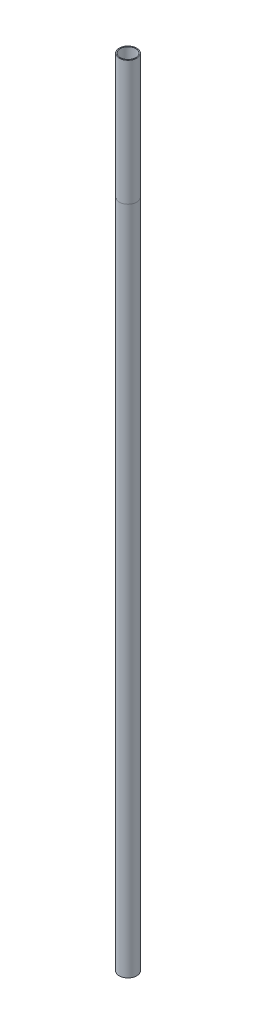
from build123d import *

# Parameters (mm, degrees)
SKETCH1_R           = 14.2875
SKETCH1_R_2         = 12.7
BOSS_EXTRUDE1_DEPTH = 1295.4
SKETCH2_R           = 12.7
BOSS_EXTRUDE2_DEPTH = 38.1


with BuildPart() as part:
    # Sketch1 → Boss-Extrude1 (new body)
    with BuildSketch(Plane(origin=(0, 0, 0), x_dir=(1, 0, 0), z_dir=(0, 1, 0))):
        Circle(SKETCH1_R)
        Circle(SKETCH1_R_2, mode=Mode.SUBTRACT)
    extrude(amount=BOSS_EXTRUDE1_DEPTH)

    # Sketch2 → Boss-Extrude2 (add)
    with BuildSketch(Plane.XZ):
        Circle(SKETCH2_R)
        with BuildLine():
            ThreePointArc((-6.985, 9.525), (-8.781051224, 8.781051224), (-9.525, 6.985))
            Line((-9.525, 6.985), (-9.525, -6.985))
            ThreePointArc((-9.525, -6.985), (-8.781051224, -8.781051224), (-6.985, -9.525))
            Line((-6.985, -9.525), (6.985, -9.525))
            ThreePointArc((6.985, -9.525), (8.781051224, -8.781051224), (9.525, -6.985))
            Line((9.525, -6.985), (9.525, 6.985))
            ThreePointArc((9.525, 6.985), (8.781051224, 8.781051224), (6.985, 9.525))
            Line((6.985, 9.525), (-6.985, 9.525))
        make_face(mode=Mode.SUBTRACT)
    extrude(amount=-BOSS_EXTRUDE2_DEPTH)


solid = part.part
